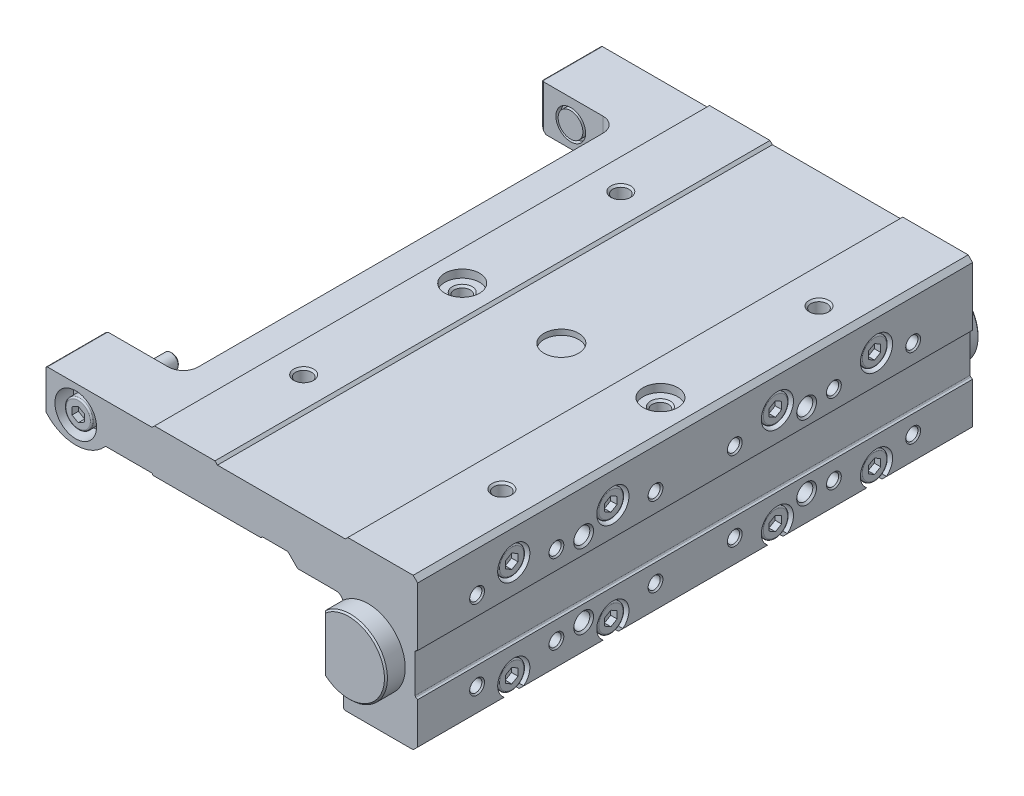
from build123d import *

# Parameters (mm, degrees)
BOSS_EXTRUDE1_DEPTH      = 56
BOSS_EXTRUDE1_DEPTH_BACK = 56
CUT_EXTRUDE1_DEPTH       = 17.6
CUT_EXTRUDE2_DEPTH       = 32
SKETCH6_W                = 3.5
SKETCH6_H                = 1.6
LPATTERN1_COUNT          = 2
LPATTERN1_PITCH          = 64
LPATTERN2_COUNT          = 2
LPATTERN2_PITCH          = 64
LPATTERN3_COUNT          = 23
LPATTERN3_PITCH          = 4
LPATTERN3_COUNT_DIR2     = 2
LPATTERN3_PITCH_DIR2     = 16
LPATTERN4_COUNT          = 2
LPATTERN4_PITCH          = 45
LPATTERN4_COUNT_DIR2     = 2
LPATTERN4_PITCH_DIR2     = 15
CUT_EXTRUDE3_DEPTH       = 3.25
CUT_EXTRUDE4_DEPTH       = 1.7
CUT_EXTRUDE5_DEPTH       = 1.7
CUT_EXTRUDE6_DEPTH       = 1.7
CUT_EXTRUDE7_DEPTH       = 1.7
CUT_EXTRUDE8_DEPTH       = 1.7
CUT_EXTRUDE9_DEPTH       = 1.7
CUT_EXTRUDE10_DEPTH      = 1.7
CUT_EXTRUDE11_DEPTH      = 1.7
BOSS_EXTRUDE2_DEPTH      = 10.2
BOSS_EXTRUDE3_DEPTH      = 10.2
CUT_EXTRUDE12_DEPTH      = 112
CUT_EXTRUDE12_DEPTH_BACK = 112
CUT_EXTRUDE13_DEPTH      = 32
CUT_EXTRUDE14_DEPTH      = 32
CUT_EXTRUDE15_DEPTH      = 4
SKETCH54_W               = 16
SKETCH54_H               = 2
CUT_EXTRUDE16_DEPTH      = 1.8
CUT_EXTRUDE17_DEPTH      = 9
CUT_EXTRUDE17_DEPTH_BACK = 9
SKETCH57_W               = 92.7
SKETCH57_H               = 20
SKETCH59_W               = 1
SKETCH59_H               = 2.5


with BuildPart() as part:
    # Sketch1 → Boss-Extrude1 (new, two sides: drawn at the far end of the back side and taken through both)
    with BuildSketch(Plane.XY.offset(-BOSS_EXTRUDE1_DEPTH_BACK)):
        with BuildLine():
            Line((-35.771059021, -8.5), (-26.7, -8.5))
            ThreePointArc((-26.7, -8.5), (-26.577525513, -8.541886117), (-26.506350833, -8.65))
            ThreePointArc((-26.506350833, -8.65), (-26.435176153, -8.758113883), (-26.312701665, -8.8))
            Line((-26.312701665, -8.8), (-4.687298335, -8.8))
            ThreePointArc((-4.687298335, -8.8), (-4.564823847, -8.758113883), (-4.493649167, -8.65))
            ThreePointArc((-4.493649167, -8.65), (-4.422474487, -8.541886117), (-4.3, -8.5))
            Line((-4.3, -8.5), (0.675735931, -8.5))
            ThreePointArc((0.675735931, -8.5), (0.790540961, -8.52283614), (0.887867966, -8.587867966))
            Line((0.887867966, -8.587867966), (2.741421356, -10.441421356))
            ThreePointArc((2.741421356, -10.441421356), (2.806306026, -10.484775907), (2.882842712, -10.5))
            Line((2.882842712, -10.5), (10.5, -10.5))
            ThreePointArc((10.5, -10.5), (11.560660172, -10.939339828), (12, -12))
            Line((12, -12), (12, -30))
            ThreePointArc((12, -30), (12.146446609, -30.353553391), (12.5, -30.5))
            Line((12.5, -30.5), (25.975735931, -30.5))
            ThreePointArc((25.975735931, -30.5), (26.090540961, -30.47716386), (26.187867966, -30.412132034))
            Line((26.187867966, -30.412132034), (27, -29.6))
            Line((27, -29.6), (27, -21.288675135))
            Line((27, -21.288675135), (26.65, -21.08660254))
            ThreePointArc((26.65, -21.08660254), (26.540192379, -20.976794919), (26.5, -20.826794919))
            Line((26.5, -20.826794919), (26.5, -13.173205081))
            ThreePointArc((26.5, -13.173205081), (26.540192379, -13.023205081), (26.65, -12.91339746))
            Line((26.65, -12.91339746), (27, -12.711324865))
            Line((27, -12.711324865), (27, -0.9))
            Line((27, -0.9), (26.1, 0))
            Line((26.1, 0), (12.9, 0))
            Line((12.9, 0), (12.4, -0.5))
            Line((12.4, -0.5), (-13.4, -0.5))
            Line((-13.4, -0.5), (-13.9, 0))
            Line((-13.9, 0), (-26.1, 0))
            Line((-26.1, 0), (-26.6, -0.5))
            Line((-26.6, -0.5), (-47.7, -0.5))
            ThreePointArc((-47.7, -0.5), (-47.912132034, -0.587867966), (-48, -0.8))
            Line((-48, -0.8), (-48, -8.389685596))
            ThreePointArc((-48, -8.389685596), (-47.981190001, -8.494242676), (-47.927118779, -8.5856883))
            ThreePointArc((-47.927118779, -8.5856883), (-42.054738895, -11.299514359), (-36.144985434, -8.668067722))
            ThreePointArc((-36.144985434, -8.668067722), (-35.976039338, -8.543948392), (-35.771059021, -8.5))
        make_face()
    extrude(amount=BOSS_EXTRUDE1_DEPTH + BOSS_EXTRUDE1_DEPTH_BACK)

    # Sketch2 → Cut-Extrude1 (cut)
    with BuildSketch(Plane(origin=(0, 0, 0), x_dir=(1, 0, 0), z_dir=(0, 1, 0))):
        with BuildLine():
            Line((-48, 44.188675135), (-48, -44.088675135))
            Line((-48, -44.088675135), (-47.5, -43.8))
            Line((-47.5, -43.8), (-35.5, -43.8))
            ThreePointArc((-35.5, -43.8), (-33.378679656, -42.921320344), (-32.5, -40.8))
            Line((-32.5, -40.8), (-32.5, 40.9))
            ThreePointArc((-32.5, 40.9), (-33.378679656, 43.021320344), (-35.5, 43.9))
            Line((-35.5, 43.9), (-47.5, 43.9))
            Line((-47.5, 43.9), (-48, 44.188675135))
        make_face()
    extrude(amount=-CUT_EXTRUDE1_DEPTH, mode=Mode.SUBTRACT)

    # Sketch3 → Cut-Extrude2 (cut)
    with BuildSketch(Plane(origin=(0, -3.5, 0), x_dir=(1, 0, 0), z_dir=(0, 1, 0))):
        with BuildLine():
            Line((5, -51.8), (13, -51.8))
            Line((13, -51.8), (13, 51.8))
            Line((13, 51.8), (5, 51.8))
            ThreePointArc((5, 51.8), (-0.656854249, 49.456854249), (-3, 43.8))
            Line((-3, 43.8), (-3, -43.8))
            ThreePointArc((-3, -43.8), (-0.656854249, -49.456854249), (5, -51.8))
        make_face()
    extrude(amount=-CUT_EXTRUDE2_DEPTH, mode=Mode.SUBTRACT)

    # Sketch4 → Cut-Revolve1 (revolve, cut)
    with BuildSketch(Plane.XY):
        Polygon((20, 0), (23.5, 0), (23.5, -1.6), (22, -1.6), (21.621, -1.979), (21.621, -10), (20, -10.935884786), align=None)
    revolve(axis=Axis((20, -10.935884786, 0), (0, 1, 0)), mode=Mode.SUBTRACT)

    # Sketch5 → Cut-Revolve2 (revolve, cut)
    with BuildSketch(Plane.XY):
        Polygon((-20, 0), (-16.5, 0), (-16.5, -1.6), (-18, -1.6), (-18.379, -1.979), (-18.379, -10), (-20, -10.935884786), align=None)
    revolve(axis=Axis((-20, -10.935884786, 0), (0, 1, 0)), mode=Mode.SUBTRACT)

    # Sketch6 → Cut-Revolve3 (revolve, cut)
    with BuildSketch(Plane.XY):
        with Locations((1.75, -0.8)):
            Rectangle(SKETCH6_W, SKETCH6_H)
    revolve(axis=Axis((0, -1.6, 0), (0, 1, 0)), mode=Mode.SUBTRACT)

    # Sketch7 → Cut-Revolve4 (revolve, cut)
    with BuildSketch(Plane.XY.offset(32)):
        Polygon((20, 0), (22, 0), (21.621, -0.379), (21.621, -10), (20, -10.935884786), align=None)
    cut_revolve4 = revolve(axis=Axis((20, -10.935884786, 32), (0, 1, 0)), mode=Mode.SUBTRACT)

    # LPattern1: Cut-Revolve4 ×2
    with Locations(*[(0, 0, -i * LPATTERN1_PITCH) for i in range(1, LPATTERN1_COUNT)]):
        add(cut_revolve4, mode=Mode.SUBTRACT)

    # Sketch9 → Cut-Revolve5 (revolve, cut)
    with BuildSketch(Plane.XY.offset(32)):
        Polygon((-20, 0), (-18, 0), (-18.379, -0.379), (-18.379, -10), (-20, -10.935884786), align=None)
    cut_revolve5 = revolve(axis=Axis((-20, -10.935884786, 32), (0, 1, 0)), mode=Mode.SUBTRACT)

    # LPattern2: Cut-Revolve5 ×2
    with Locations(*[(0, 0, -i * LPATTERN2_PITCH) for i in range(1, LPATTERN2_COUNT)]):
        add(cut_revolve5, mode=Mode.SUBTRACT)

    # Sketch11 → Cut-Revolve6 (revolve, cut)
    with BuildSketch(Plane(origin=(0, -9, 0), x_dir=(1, 0, 0), z_dir=(0, 1, 0))):
        Polygon((19.290147844, 44), (20, 45.2295), (26.7295, 45.2295), (27, 45.5), (27, 44), align=None)
    cut_revolve6 = revolve(axis=Axis((27, -9, -44), (-1, 0, 0)), mode=Mode.SUBTRACT)

    # LPattern3: Cut-Revolve6 23 × 2, 34 skipped
    with Locations(*[(0, -j * LPATTERN3_PITCH_DIR2, i * LPATTERN3_PITCH) for i in range(LPATTERN3_COUNT) for j in range(LPATTERN3_COUNT_DIR2) if (i, j) not in ((0, 0), (1, 0), (1, 1), (2, 0), (2, 1), (3, 0), (3, 1), (5, 0), (5, 1), (6, 0), (6, 1), (7, 0), (7, 1), (8, 0), (8, 1), (10, 0), (10, 1), (11, 0), (11, 1), (12, 0), (12, 1), (14, 0), (14, 1), (15, 0), (15, 1), (16, 0), (16, 1), (17, 0), (17, 1), (19, 0), (19, 1), (20, 0), (20, 1), (21, 0), (21, 1))]):
        add(cut_revolve6, mode=Mode.SUBTRACT)

    # Sketch13 → Cut-Revolve7 (revolve, cut)
    with BuildSketch(Plane(origin=(0, -9.5, 0), x_dir=(1, 0, 0), z_dir=(0, 1, 0))):
        Polygon((19.064115214, 22.5), (20, 24.121), (26.621, 24.121), (27, 24.5), (27, 22.5), align=None)
    cut_revolve7 = revolve(axis=Axis((27, -9.5, -22.5), (-1, 0, 0)), mode=Mode.SUBTRACT)

    # LPattern4: Cut-Revolve7 2 × 2
    with Locations(*[(0, -j * LPATTERN4_PITCH_DIR2, i * LPATTERN4_PITCH) for i in range(LPATTERN4_COUNT) for j in range(LPATTERN4_COUNT_DIR2) if (i, j) != (0, 0)]):
        add(cut_revolve7, mode=Mode.SUBTRACT)

    # Sketch15 → Cut-Extrude3 (cut)
    with BuildSketch(Plane(origin=(0, -30.5, 0), x_dir=(1, 0, 0), z_dir=(0, 1, 0))):
        with BuildLine():
            Line((23.6, -34.8), (23.6, -38.4))
            ThreePointArc((23.6, -38.4), (23.658578644, -38.541421356), (23.8, -38.6))
            Line((23.8, -38.6), (40, -38.6))
            Line((40, -38.6), (40, 38.6))
            Line((40, 38.6), (23.8, 38.6))
            ThreePointArc((23.8, 38.6), (23.658578644, 38.541421356), (23.6, 38.4))
            Line((23.6, 38.4), (23.6, 34.8))
            ThreePointArc((23.6, 34.8), (23.658578644, 34.658578644), (23.8, 34.6))
            Line((23.8, 34.6), (35, 34.6))
            Line((35, 34.6), (35, 18.6))
            Line((35, 18.6), (23.8, 18.6))
            ThreePointArc((23.8, 18.6), (23.658578644, 18.541421356), (23.6, 18.4))
            Line((23.6, 18.4), (23.6, 14.8))
            ThreePointArc((23.6, 14.8), (23.658578644, 14.658578644), (23.8, 14.6))
            Line((23.8, 14.6), (35, 14.6))
            Line((35, 14.6), (35, -14.6))
            Line((35, -14.6), (23.8, -14.6))
            ThreePointArc((23.8, -14.6), (23.658578644, -14.658578644), (23.6, -14.8))
            Line((23.6, -14.8), (23.6, -18.4))
            ThreePointArc((23.6, -18.4), (23.658578644, -18.541421356), (23.8, -18.6))
            Line((23.8, -18.6), (35, -18.6))
            Line((35, -18.6), (35, -34.6))
            Line((35, -34.6), (23.8, -34.6))
            ThreePointArc((23.8, -34.6), (23.658578644, -34.658578644), (23.6, -34.8))
        make_face()
    extrude(amount=CUT_EXTRUDE3_DEPTH, mode=Mode.SUBTRACT)

    # Sketch16 → Cut-Revolve8 (revolve, cut)
    with BuildSketch(Plane(origin=(0, -7, 0), x_dir=(1, 0, 0), z_dir=(0, 1, 0))):
        with BuildLine():
            Line((23.6, 36.6), (23.6, 39.65))
            ThreePointArc((23.6, 39.65), (23.658578644, 39.791421356), (23.8, 39.85))
            Line((23.8, 39.85), (27, 39.85))
            Line((27, 39.85), (27, 36.6))
            Line((27, 36.6), (23.6, 36.6))
        make_face()
    revolve(axis=Axis((27, -7, -36.6), (-1, 0, 0)), mode=Mode.SUBTRACT)

    # Sketch18 → Cut-Revolve9 (revolve, cut)
    with BuildSketch(Plane(origin=(0, -27, 0), x_dir=(1, 0, 0), z_dir=(0, 1, 0))):
        with BuildLine():
            Line((23.6, 36.6), (23.6, 39.65))
            ThreePointArc((23.6, 39.65), (23.658578644, 39.791421356), (23.8, 39.85))
            Line((23.8, 39.85), (27, 39.85))
            Line((27, 39.85), (27, 36.6))
            Line((27, 36.6), (23.6, 36.6))
        make_face()
    revolve(axis=Axis((27, -27, -36.6), (-1, 0, 0)), mode=Mode.SUBTRACT)

    # Sketch19 → Cut-Revolve10 (revolve, cut)
    with BuildSketch(Plane(origin=(0, -7, 0), x_dir=(1, 0, 0), z_dir=(0, 1, 0))):
        with BuildLine():
            Line((23.6, 16.6), (23.6, 19.65))
            ThreePointArc((23.6, 19.65), (23.658578644, 19.791421356), (23.8, 19.85))
            Line((23.8, 19.85), (27, 19.85))
            Line((27, 19.85), (27, 16.6))
            Line((27, 16.6), (23.6, 16.6))
        make_face()
    revolve(axis=Axis((27, -7, -16.6), (-1, 0, 0)), mode=Mode.SUBTRACT)

    # Sketch20 → Cut-Revolve11 (revolve, cut)
    with BuildSketch(Plane(origin=(0, -27, 0), x_dir=(1, 0, 0), z_dir=(0, 1, 0))):
        with BuildLine():
            Line((23.6, 16.6), (23.6, 19.65))
            ThreePointArc((23.6, 19.65), (23.658578644, 19.791421356), (23.8, 19.85))
            Line((23.8, 19.85), (27, 19.85))
            Line((27, 19.85), (27, 16.6))
            Line((27, 16.6), (23.6, 16.6))
        make_face()
    revolve(axis=Axis((27, -27, -16.6), (-1, 0, 0)), mode=Mode.SUBTRACT)

    # Sketch21 → Cut-Revolve12 (revolve, cut)
    with BuildSketch(Plane(origin=(0, -7, 0), x_dir=(1, 0, 0), z_dir=(0, 1, 0))):
        with BuildLine():
            Line((23.6, -16.6), (23.6, -13.55))
            ThreePointArc((23.6, -13.55), (23.658578644, -13.408578644), (23.8, -13.35))
            Line((23.8, -13.35), (27, -13.35))
            Line((27, -13.35), (27, -16.6))
            Line((27, -16.6), (23.6, -16.6))
        make_face()
    revolve(axis=Axis((27, -7, 16.6), (-1, 0, 0)), mode=Mode.SUBTRACT)

    # Sketch22 → Cut-Revolve13 (revolve, cut)
    with BuildSketch(Plane(origin=(0, -27, 0), x_dir=(1, 0, 0), z_dir=(0, 1, 0))):
        with BuildLine():
            Line((23.6, -16.6), (23.6, -13.55))
            ThreePointArc((23.6, -13.55), (23.658578644, -13.408578644), (23.8, -13.35))
            Line((23.8, -13.35), (27, -13.35))
            Line((27, -13.35), (27, -16.6))
            Line((27, -16.6), (23.6, -16.6))
        make_face()
    revolve(axis=Axis((27, -27, 16.6), (-1, 0, 0)), mode=Mode.SUBTRACT)

    # Sketch23 → Cut-Revolve14 (revolve, cut)
    with BuildSketch(Plane(origin=(0, -7, 0), x_dir=(1, 0, 0), z_dir=(0, 1, 0))):
        with BuildLine():
            Line((23.6, -36.6), (23.6, -33.55))
            ThreePointArc((23.6, -33.55), (23.658578644, -33.408578644), (23.8, -33.35))
            Line((23.8, -33.35), (27, -33.35))
            Line((27, -33.35), (27, -36.6))
            Line((27, -36.6), (23.6, -36.6))
        make_face()
    revolve(axis=Axis((27, -7, 36.6), (-1, 0, 0)), mode=Mode.SUBTRACT)

    # Sketch24 → Cut-Revolve15 (revolve, cut)
    with BuildSketch(Plane(origin=(0, -27, 0), x_dir=(1, 0, 0), z_dir=(0, 1, 0))):
        with BuildLine():
            Line((23.6, -36.6), (23.6, -33.55))
            ThreePointArc((23.6, -33.55), (23.658578644, -33.408578644), (23.8, -33.35))
            Line((23.8, -33.35), (27, -33.35))
            Line((27, -33.35), (27, -36.6))
            Line((27, -36.6), (23.6, -36.6))
        make_face()
    revolve(axis=Axis((27, -27, 36.6), (-1, 0, 0)), mode=Mode.SUBTRACT)

    # Sketch25 → Revolve1 (revolve)
    with BuildSketch(Plane(origin=(0, -7, 0), x_dir=(1, 0, 0), z_dir=(0, 1, 0))):
        with BuildLine():
            Line((23.6, 36.6), (23.6, 39.35))
            Line((23.6, 39.35), (26.3, 39.35))
            ThreePointArc((26.3, 39.35), (26.512132034, 39.262132034), (26.6, 39.05))
            Line((26.6, 39.05), (26.6, 36.6))
            Line((26.6, 36.6), (23.6, 36.6))
        make_face()
    revolve(axis=Axis((27, -7, -36.6), (-1, 0, 0)))

    # Sketch27 → Revolve2 (revolve)
    with BuildSketch(Plane(origin=(0, -27, 0), x_dir=(1, 0, 0), z_dir=(0, 1, 0))):
        with BuildLine():
            Line((23.6, 36.6), (23.6, 39.35))
            Line((23.6, 39.35), (26.3, 39.35))
            ThreePointArc((26.3, 39.35), (26.512132034, 39.262132034), (26.6, 39.05))
            Line((26.6, 39.05), (26.6, 36.6))
            Line((26.6, 36.6), (23.6, 36.6))
        make_face()
    revolve(axis=Axis((27, -27, -36.6), (-1, 0, 0)))

    # Sketch28 → Revolve3 (revolve)
    with BuildSketch(Plane(origin=(0, -7, 0), x_dir=(1, 0, 0), z_dir=(0, 1, 0))):
        with BuildLine():
            Line((23.6, 16.6), (23.6, 19.35))
            Line((23.6, 19.35), (26.3, 19.35))
            ThreePointArc((26.3, 19.35), (26.512132034, 19.262132034), (26.6, 19.05))
            Line((26.6, 19.05), (26.6, 16.6))
            Line((26.6, 16.6), (23.6, 16.6))
        make_face()
    revolve(axis=Axis((27, -7, -16.6), (-1, 0, 0)))

    # Sketch29 → Revolve4 (revolve)
    with BuildSketch(Plane(origin=(0, -27, 0), x_dir=(1, 0, 0), z_dir=(0, 1, 0))):
        with BuildLine():
            Line((23.6, 16.6), (23.6, 19.35))
            Line((23.6, 19.35), (26.3, 19.35))
            ThreePointArc((26.3, 19.35), (26.512132034, 19.262132034), (26.6, 19.05))
            Line((26.6, 19.05), (26.6, 16.6))
            Line((26.6, 16.6), (23.6, 16.6))
        make_face()
    revolve(axis=Axis((27, -27, -16.6), (-1, 0, 0)))

    # Sketch30 → Revolve5 (revolve)
    with BuildSketch(Plane(origin=(0, -7, 0), x_dir=(1, 0, 0), z_dir=(0, 1, 0))):
        with BuildLine():
            Line((23.6, -16.6), (23.6, -13.85))
            Line((23.6, -13.85), (26.3, -13.85))
            ThreePointArc((26.3, -13.85), (26.512132034, -13.937867966), (26.6, -14.15))
            Line((26.6, -14.15), (26.6, -16.6))
            Line((26.6, -16.6), (23.6, -16.6))
        make_face()
    revolve(axis=Axis((27, -7, 16.6), (-1, 0, 0)))

    # Sketch31 → Revolve6 (revolve)
    with BuildSketch(Plane(origin=(0, -27, 0), x_dir=(1, 0, 0), z_dir=(0, 1, 0))):
        with BuildLine():
            Line((23.6, -16.6), (23.6, -13.85))
            Line((23.6, -13.85), (26.3, -13.85))
            ThreePointArc((26.3, -13.85), (26.512132034, -13.937867966), (26.6, -14.15))
            Line((26.6, -14.15), (26.6, -16.6))
            Line((26.6, -16.6), (23.6, -16.6))
        make_face()
    revolve(axis=Axis((27, -27, 16.6), (-1, 0, 0)))

    # Sketch32 → Revolve7 (revolve)
    with BuildSketch(Plane(origin=(0, -7, 0), x_dir=(1, 0, 0), z_dir=(0, 1, 0))):
        with BuildLine():
            Line((23.6, -36.6), (23.6, -33.85))
            Line((23.6, -33.85), (26.3, -33.85))
            ThreePointArc((26.3, -33.85), (26.512132034, -33.937867966), (26.6, -34.15))
            Line((26.6, -34.15), (26.6, -36.6))
            Line((26.6, -36.6), (23.6, -36.6))
        make_face()
    revolve(axis=Axis((27, -7, 36.6), (-1, 0, 0)))

    # Sketch33 → Revolve8 (revolve)
    with BuildSketch(Plane(origin=(0, -27, 0), x_dir=(1, 0, 0), z_dir=(0, 1, 0))):
        with BuildLine():
            Line((23.6, -36.6), (23.6, -33.85))
            Line((23.6, -33.85), (26.3, -33.85))
            ThreePointArc((26.3, -33.85), (26.512132034, -33.937867966), (26.6, -34.15))
            Line((26.6, -34.15), (26.6, -36.6))
            Line((26.6, -36.6), (23.6, -36.6))
        make_face()
    revolve(axis=Axis((27, -27, 36.6), (-1, 0, 0)))

    # Sketch34 → Cut-Extrude4 (cut)
    with BuildSketch(Plane(origin=(27, 0, 0), x_dir=(0, 0, -1), z_dir=(1, 0, 0))):
        Polygon((35.35, -7.721687836), (36.6, -8.443375673), (37.85, -7.721687836), (37.85, -6.278312164), (36.6, -5.556624327), (35.35, -6.278312164), align=None)
    extrude(amount=-CUT_EXTRUDE4_DEPTH, mode=Mode.SUBTRACT)

    # Sketch36 → Cut-Extrude5 (cut)
    with BuildSketch(Plane(origin=(27, 0, 0), x_dir=(0, 0, -1), z_dir=(1, 0, 0))):
        Polygon((35.35, -27.721687836), (36.6, -28.443375673), (37.85, -27.721687836), (37.85, -26.278312164), (36.6, -25.556624327), (35.35, -26.278312164), align=None)
    extrude(amount=-CUT_EXTRUDE5_DEPTH, mode=Mode.SUBTRACT)

    # Sketch37 → Cut-Extrude6 (cut)
    with BuildSketch(Plane(origin=(27, 0, 0), x_dir=(0, 0, -1), z_dir=(1, 0, 0))):
        Polygon((15.35, -7.721687836), (16.6, -8.443375673), (17.85, -7.721687836), (17.85, -6.278312164), (16.6, -5.556624327), (15.35, -6.278312164), align=None)
    extrude(amount=-CUT_EXTRUDE6_DEPTH, mode=Mode.SUBTRACT)

    # Sketch38 → Cut-Extrude7 (cut)
    with BuildSketch(Plane(origin=(27, 0, 0), x_dir=(0, 0, -1), z_dir=(1, 0, 0))):
        Polygon((15.35, -27.721687836), (16.6, -28.443375673), (17.85, -27.721687836), (17.85, -26.278312164), (16.6, -25.556624327), (15.35, -26.278312164), align=None)
    extrude(amount=-CUT_EXTRUDE7_DEPTH, mode=Mode.SUBTRACT)

    # Sketch39 → Cut-Extrude8 (cut)
    with BuildSketch(Plane(origin=(27, 0, 0), x_dir=(0, 0, -1), z_dir=(1, 0, 0))):
        Polygon((-17.85, -7.721687836), (-16.6, -8.443375673), (-15.35, -7.721687836), (-15.35, -6.278312164), (-16.6, -5.556624327), (-17.85, -6.278312164), align=None)
    extrude(amount=-CUT_EXTRUDE8_DEPTH, mode=Mode.SUBTRACT)

    # Sketch40 → Cut-Extrude9 (cut)
    with BuildSketch(Plane(origin=(27, 0, 0), x_dir=(0, 0, -1), z_dir=(1, 0, 0))):
        Polygon((-17.85, -27.721687836), (-16.6, -28.443375673), (-15.35, -27.721687836), (-15.35, -26.278312164), (-16.6, -25.556624327), (-17.85, -26.278312164), align=None)
    extrude(amount=-CUT_EXTRUDE9_DEPTH, mode=Mode.SUBTRACT)

    # Sketch41 → Cut-Extrude10 (cut)
    with BuildSketch(Plane(origin=(27, 0, 0), x_dir=(0, 0, -1), z_dir=(1, 0, 0))):
        Polygon((-37.85, -7.721687836), (-36.6, -8.443375673), (-35.35, -7.721687836), (-35.35, -6.278312164), (-36.6, -5.556624327), (-37.85, -6.278312164), align=None)
    extrude(amount=-CUT_EXTRUDE10_DEPTH, mode=Mode.SUBTRACT)

    # Sketch42 → Cut-Extrude11 (cut)
    with BuildSketch(Plane(origin=(27, 0, 0), x_dir=(0, 0, -1), z_dir=(1, 0, 0))):
        Polygon((-37.85, -27.721687836), (-36.6, -28.443375673), (-35.35, -27.721687836), (-35.35, -26.278312164), (-36.6, -25.556624327), (-37.85, -26.278312164), align=None)
    extrude(amount=-CUT_EXTRUDE11_DEPTH, mode=Mode.SUBTRACT)

    # Sketch43 → Boss-Extrude2 (add)
    with BuildSketch(Plane(origin=(13, 0, 0), x_dir=(0, 0, -1), z_dir=(1, 0, 0))):
        with BuildLine():
            Line((2.8, -4.95), (2.8, -29.05))
            ThreePointArc((2.8, -29.05), (2.946446609, -29.403553391), (3.3, -29.55))
            Line((3.3, -29.55), (5.8, -29.55))
            Line((5.8, -29.55), (6.45, -30.2))
            Line((6.45, -30.2), (9.6, -30.2))
            Line((9.6, -30.2), (9.6, -30.3))
            Line((9.6, -30.3), (43.6, -30.3))
            Line((43.6, -30.3), (43.6, -30.2))
            Line((43.6, -30.2), (46.75, -30.2))
            Line((46.75, -30.2), (47.4, -29.55))
            Line((47.4, -29.55), (49.9, -29.55))
            ThreePointArc((49.9, -29.55), (50.253553391, -29.403553391), (50.4, -29.05))
            Line((50.4, -29.05), (50.4, -4.95))
            ThreePointArc((50.4, -4.95), (50.253553391, -4.596446609), (49.9, -4.45))
            Line((49.9, -4.45), (47.4, -4.45))
            Line((47.4, -4.45), (46.75, -3.8))
            Line((46.75, -3.8), (43.6, -3.8))
            Line((43.6, -3.8), (43.6, -3.7))
            Line((43.6, -3.7), (9.6, -3.7))
            Line((9.6, -3.7), (9.6, -3.8))
            Line((9.6, -3.8), (6.45, -3.8))
            Line((6.45, -3.8), (5.8, -4.45))
            Line((5.8, -4.45), (3.3, -4.45))
            ThreePointArc((3.3, -4.45), (2.946446609, -4.596446609), (2.8, -4.95))
        make_face()
    extrude(amount=-BOSS_EXTRUDE2_DEPTH)

    # Sketch44 → Boss-Extrude3 (add)
    with BuildSketch(Plane(origin=(13, 0, 0), x_dir=(0, 0, -1), z_dir=(1, 0, 0))):
        with BuildLine():
            Line((-49.9, -29.55), (-47.4, -29.55))
            Line((-47.4, -29.55), (-46.75, -30.2))
            Line((-46.75, -30.2), (-43.6, -30.2))
            Line((-43.6, -30.2), (-43.6, -30.3))
            Line((-43.6, -30.3), (-9.6, -30.3))
            Line((-9.6, -30.3), (-9.6, -30.2))
            Line((-9.6, -30.2), (-6.45, -30.2))
            Line((-6.45, -30.2), (-5.8, -29.55))
            Line((-5.8, -29.55), (-3.3, -29.55))
            ThreePointArc((-3.3, -29.55), (-2.946446609, -29.403553391), (-2.8, -29.05))
            Line((-2.8, -29.05), (-2.8, -4.95))
            ThreePointArc((-2.8, -4.95), (-2.946446609, -4.596446609), (-3.3, -4.45))
            Line((-3.3, -4.45), (-5.8, -4.45))
            Line((-5.8, -4.45), (-6.45, -3.8))
            Line((-6.45, -3.8), (-9.6, -3.8))
            Line((-9.6, -3.8), (-9.6, -3.7))
            Line((-9.6, -3.7), (-43.6, -3.7))
            Line((-43.6, -3.7), (-43.6, -3.8))
            Line((-43.6, -3.8), (-46.75, -3.8))
            Line((-46.75, -3.8), (-47.4, -4.45))
            Line((-47.4, -4.45), (-49.9, -4.45))
            ThreePointArc((-49.9, -4.45), (-50.253553391, -4.596446609), (-50.4, -4.95))
            Line((-50.4, -4.95), (-50.4, -29.05))
            ThreePointArc((-50.4, -29.05), (-50.253553391, -29.403553391), (-49.9, -29.55))
        make_face()
    extrude(amount=-BOSS_EXTRUDE3_DEPTH)

    # Sketch45 → Cut-Extrude12 (cut, two sides: drawn at the far end of the back side and taken through both)
    with BuildSketch(Plane.XY.offset(-CUT_EXTRUDE12_DEPTH_BACK)):
        with BuildLine():
            Line((0, -23), (3.95, -23))
            ThreePointArc((3.95, -23), (5.2, -21.75), (6.45, -23))
            Line((6.45, -23), (7.2, -23))
            ThreePointArc((7.2, -23), (7.412132034, -22.912132034), (7.5, -22.7))
            Line((7.5, -22.7), (7.5, -11.3))
            ThreePointArc((7.5, -11.3), (7.412132034, -11.087867966), (7.2, -11))
            Line((7.2, -11), (6.45, -11))
            ThreePointArc((6.45, -11), (5.2, -12.25), (3.95, -11))
            Line((3.95, -11), (0, -11))
            Line((0, -11), (0, -23))
        make_face()
    extrude(amount=CUT_EXTRUDE12_DEPTH + CUT_EXTRUDE12_DEPTH_BACK, mode=Mode.SUBTRACT)

    # Sketch46 → Revolve9 (revolve)
    with BuildSketch(Plane(origin=(17, 0, 0), x_dir=(0, 0, -1), z_dir=(1, 0, 0))):
        Polygon((56, -17), (56, -9.5), (59.6, -9.5), (59.9, -9.8), (59.9, -17), align=None)
    revolve(axis=Axis((17, -17, -59.9), (0, 0, 1)))

    # Sketch47 → Revolve10 (revolve)
    with BuildSketch(Plane(origin=(17, 0, 0), x_dir=(0, 0, -1), z_dir=(1, 0, 0))):
        Polygon((-59.9, -17), (-59.9, -9.8), (-59.6, -9.5), (-56, -9.5), (-56, -17), align=None)
    revolve(axis=Axis((17, -17, 56), (0, 0, 1)))

    # Sketch48 → Cut-Extrude13 (cut)
    with BuildSketch(Plane(origin=(0, 0, 0), x_dir=(1, 0, 0), z_dir=(0, 1, 0))):
        Polygon((2, 59.9), (2, 56), (12, 56), (12, 59.6), (12.3, 59.9), align=None)
    extrude(amount=-CUT_EXTRUDE13_DEPTH, mode=Mode.SUBTRACT)

    # Sketch49 → Cut-Extrude14 (cut)
    with BuildSketch(Plane(origin=(0, 0, 0), x_dir=(1, 0, 0), z_dir=(0, 1, 0))):
        Polygon((2, -59.9), (12.3, -59.9), (12, -59.6), (12, -56), (2, -56), align=None)
    extrude(amount=-CUT_EXTRUDE14_DEPTH, mode=Mode.SUBTRACT)

    # Sketch50 → Cut-Revolve16 (revolve, cut)
    with BuildSketch(Plane(origin=(-42, 0, 0), x_dir=(0, 0, -1), z_dir=(1, 0, 0))):
        Polygon((55.4, -5.25), (55.4, -2.25), (51.5, -2.25), (51.5, -1.75), (56, -1.75), (56, -5.25), align=None)
    revolve(axis=Axis((-42, -5.25, -56), (0, 0, 1)), mode=Mode.SUBTRACT)

    # Sketch51 → Cut-Extrude15 (cut)
    with BuildSketch(Plane.XY.offset(-56)):
        Polygon((-43.5, -6.116025404), (-42, -6.982050808), (-40.5, -6.116025404), (-40.5, -4.383974596), (-42, -3.517949192), (-43.5, -4.383974596), align=None)
    extrude(amount=CUT_EXTRUDE15_DEPTH, mode=Mode.SUBTRACT)

    # Sketch52 → Cut-Revolve17 (revolve, cut)
    with BuildSketch(Plane(origin=(-42, 0, 0), x_dir=(0, 0, -1), z_dir=(1, 0, 0))):
        with BuildLine():
            Line((-56, -6), (-56, -1.8))
            Line((-56, -1.8), (-52.2, -1.8))
            ThreePointArc((-52.2, -1.8), (-52.058578644, -1.858578644), (-52, -2))
            Line((-52, -2), (-52.5, -2))
            Line((-52.5, -2), (-52.5, -6))
            Line((-52.5, -6), (-56, -6))
        make_face()
    revolve(axis=Axis((-42, -6, 52.5), (0, 0, 1)), mode=Mode.SUBTRACT)

    # Sketch53 → Revolve11 (revolve)
    with BuildSketch(Plane(origin=(-42, 0, 0), x_dir=(0, 0, -1), z_dir=(1, 0, 0))):
        with BuildLine():
            Line((-55.5, -6.2), (-55.5, -3.75))
            ThreePointArc((-55.5, -3.75), (-55.412132034, -3.537867966), (-55.2, -3.45))
            Line((-55.2, -3.45), (-52.5, -3.45))
            Line((-52.5, -3.45), (-52.5, -6.2))
            Line((-52.5, -6.2), (-55.5, -6.2))
        make_face()
    revolve(axis=Axis((-42, -6.2, 52.5), (0, 0, 1)))

    # Sketch54 → Cut-Revolve18 (revolve, cut)
    with BuildSketch(Plane(origin=(-42, 0, 0), x_dir=(0, 0, -1), z_dir=(1, 0, 0))):
        with Locations((-44, -5)):
            Rectangle(SKETCH54_W, SKETCH54_H)
    revolve(axis=Axis((-42, -6, 36), (0, 0, 1)), mode=Mode.SUBTRACT)

    # Sketch55 → Cut-Extrude16 (cut)
    with BuildSketch(Plane.XY.offset(56)):
        Polygon((-43.25, -6.921687836), (-42, -7.643375673), (-40.75, -6.921687836), (-40.75, -5.478312164), (-42, -4.756624327), (-43.25, -5.478312164), align=None)
    extrude(amount=-CUT_EXTRUDE16_DEPTH, mode=Mode.SUBTRACT)

    # Sketch56 → Revolve12 (revolve)
    with BuildSketch(Plane(origin=(-42, 0, 0), x_dir=(0, 0, -1), z_dir=(1, 0, 0))):
        Polygon((-52.5, -6.2), (-52.5, -4.7), (-36.8065, -4.7), (-36.5, -5.0065), (-36.5, -6.2), align=None)
    revolve(axis=Axis((-42, -6.2, 36.5), (0, 0, 1)))

    # Sketch57 → Cut-Extrude17 (cut, two sides: drawn at the far end of the back side and taken through both)
    with BuildSketch(Plane(origin=(-42, 0, 0), x_dir=(0, 0, -1), z_dir=(1, 0, 0)).offset(-CUT_EXTRUDE17_DEPTH_BACK)):
        with Locations((0, -19.5)):
            Rectangle(SKETCH57_W, SKETCH57_H)
    extrude(amount=CUT_EXTRUDE17_DEPTH + CUT_EXTRUDE17_DEPTH_BACK, mode=Mode.SUBTRACT)

    # Sketch58 → Cut-Revolve19 (revolve, cut)
    with BuildSketch(Plane(origin=(-42, 0, 0), x_dir=(0, 0, -1), z_dir=(1, 0, 0))):
        Polygon((42.9, -5.25), (42.9, -2.25), (44.9, -2.25), (44.9, -2.75), (43.9, -2.75), (43.9, -5.25), align=None)
    revolve(axis=Axis((-42, -5.25, -44.9), (0, 0, 1)), mode=Mode.SUBTRACT)

    # Sketch59 → Revolve13 (revolve)
    with BuildSketch(Plane(origin=(-42, 0, 0), x_dir=(0, 0, -1), z_dir=(1, 0, 0))):
        with Locations((44.35, -4)):
            Rectangle(SKETCH59_W, SKETCH59_H)
    revolve(axis=Axis((-42, -5.25, -44.85), (0, 0, 1)))


solid = part.part
